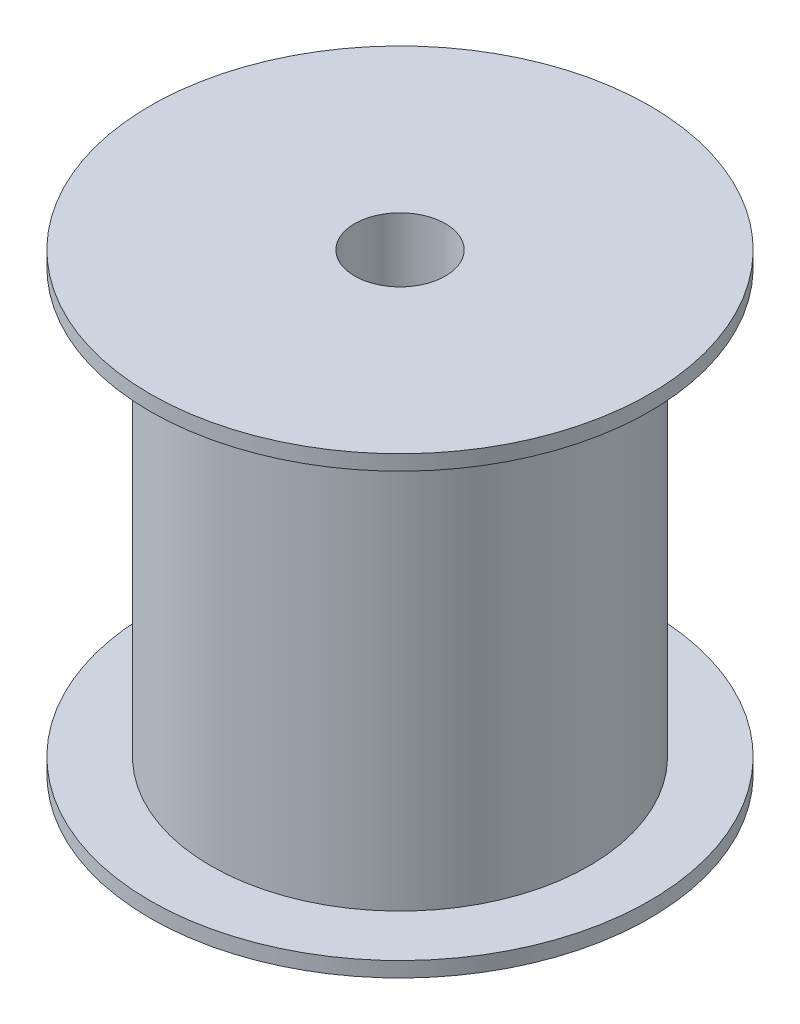
from build123d import *

# Parameters (mm, degrees)
ESQUISSE1_R             = 12.5
BOSS_EXTRU_1_DEPTH      = 30
ESQUISSE1_3_R           = 16.5
ESQUISSE1_3_R_2         = 12.5
BOSS_EXTRU_2_DEPTH      = 1
BOSS_EXTRU_3_START      = -1
ESQUISSE2_R             = 16.5
BOSS_EXTRU_3_DEPTH      = 1
ESQUISSE3_R             = 1.1525
ENL_V_MAT_EXTRU_1_DEPTH = 6
ESQUISSE4_R             = 3
ENL_V_MAT_EXTRU_2_DEPTH = 5


with BuildPart() as part:
    # Esquisse1 → Boss.-Extru.1 (new body)
    with BuildSketch(Plane(origin=(0, 0, 0), x_dir=(1, 0, 0), z_dir=(0, 1, 0))):
        Circle(ESQUISSE1_R)
    extrude(amount=BOSS_EXTRU_1_DEPTH)

    # Esquisse1_3 → Boss.-Extru.2 (add)
    with BuildSketch(Plane(origin=(0, 0, 0), x_dir=(1, 0, 0), z_dir=(0, 1, 0))):
        Circle(ESQUISSE1_3_R)
        Circle(ESQUISSE1_3_R_2, mode=Mode.SUBTRACT)
    extrude(amount=BOSS_EXTRU_2_DEPTH)

    # Esquisse2 → Boss.-Extru.3 (add)
    with BuildSketch(Plane(origin=(0, 30, 0), x_dir=(1, 0, 0), z_dir=(0, 1, 0)).offset(BOSS_EXTRU_3_START)):
        Circle(ESQUISSE2_R)
    extrude(amount=BOSS_EXTRU_3_DEPTH)

    # Esquisse3 → Enlèv. mat.-Extru.1 (cut)
    with BuildSketch(Plane.XZ):
        Circle(ESQUISSE3_R)
    extrude(amount=-ENL_V_MAT_EXTRU_1_DEPTH, mode=Mode.SUBTRACT)

    # Esquisse4 → Enlèv. mat.-Extru.2 (cut)
    with BuildSketch(Plane(origin=(0, 30, 0), x_dir=(1, 0, 0), z_dir=(0, 1, 0))):
        Circle(ESQUISSE4_R)
    extrude(amount=-ENL_V_MAT_EXTRU_2_DEPTH, mode=Mode.SUBTRACT)


solid = part.part
